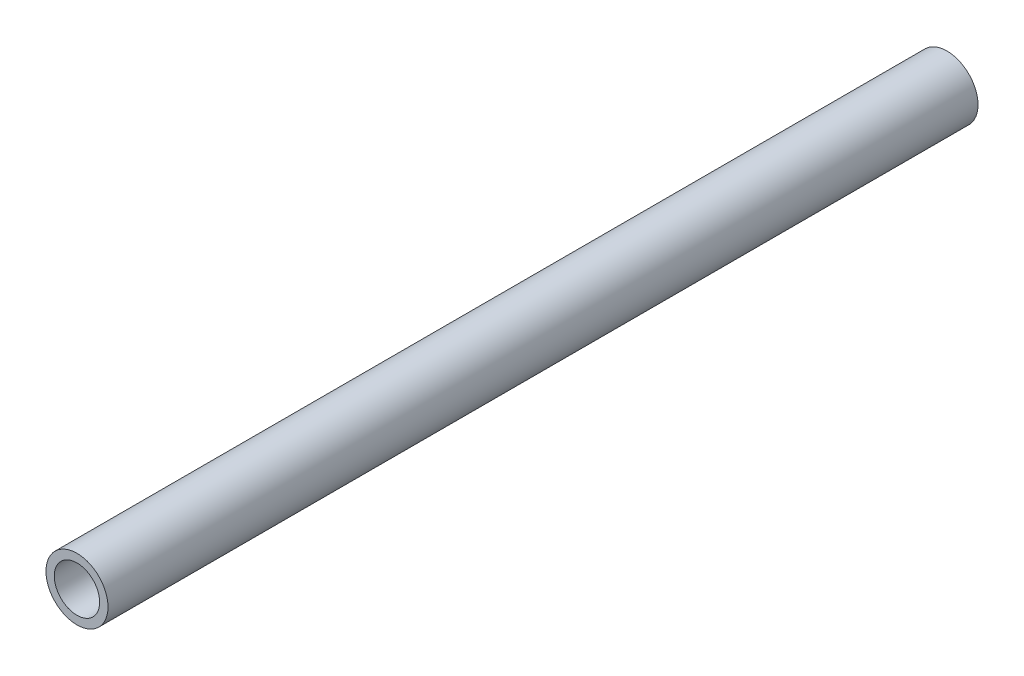
from build123d import *

# Parameters (mm, degrees)
CROQUIS1_R              = 10.7
CROQUIS1_R_2            = 7.825
SALIENTE_EXTRUIR1_DEPTH = 150


with BuildPart() as part:
    # Croquis1 → Saliente-Extruir1 (new body, symmetric)
    with BuildSketch(Plane.XY):
        Circle(CROQUIS1_R)
        Circle(CROQUIS1_R_2, mode=Mode.SUBTRACT)
    extrude(amount=SALIENTE_EXTRUIR1_DEPTH, both=True)


solid = part.part
